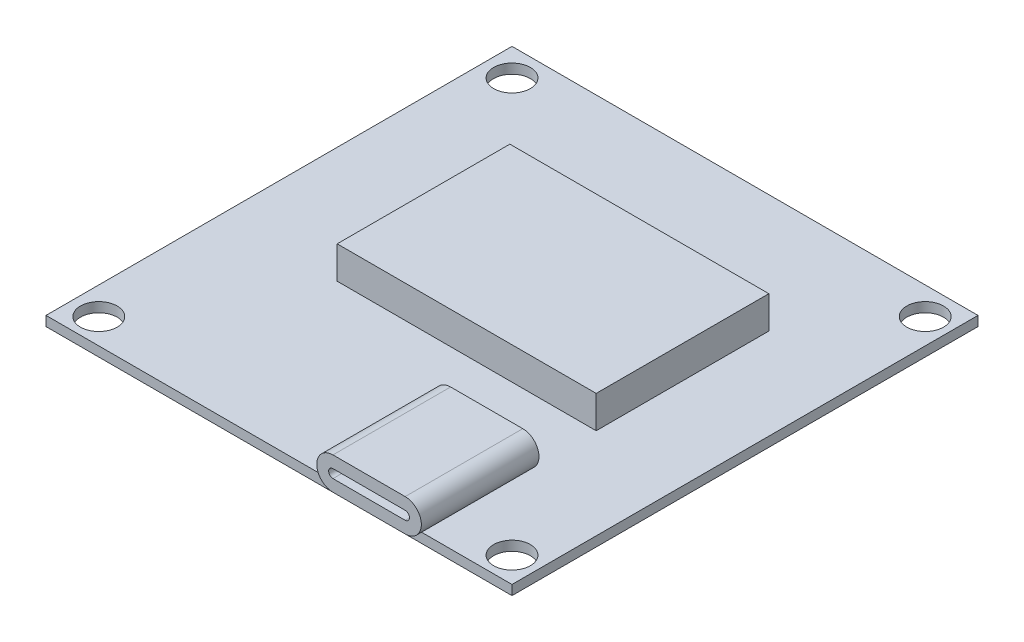
from build123d import *

# Parameters (mm, degrees)
SKETCH1_W                = 43.18
SKETCH1_H                = 43.18
BOSS_EXTRUDE1_DEPTH      = 0.9
SKETCH2_R                = 1.7
CUT_EXTRUDE1_DEPTH       = 0.9
CIRPATTERN1_COUNT        = 4
BOSS_EXTRUDE2_DEPTH      = 0.9
BOSS_EXTRUDE2_DEPTH_BACK = 10
SKETCH5_W                = 24
SKETCH5_H                = 16
BOSS_EXTRUDE3_DEPTH      = 3


with BuildPart() as part:
    # Sketch1 → Boss-Extrude1 (new body)
    with BuildSketch(Plane(origin=(0, 0, 0), x_dir=(1, 0, 0), z_dir=(0, 1, 0))):
        with Locations((21.59, 21.59)):
            Rectangle(SKETCH1_W, SKETCH1_H)
    extrude(amount=BOSS_EXTRUDE1_DEPTH)

    # Sketch2 → Cut-Extrude1 (cut)
    with BuildSketch(Plane(origin=(0, 0.9, 0), x_dir=(1, 0, 0), z_dir=(0, 1, 0))):
        with Locations((2.54, 40.64)):
            Circle(SKETCH2_R)
    cut_extrude1 = extrude(amount=-CUT_EXTRUDE1_DEPTH, mode=Mode.SUBTRACT)

    # CirPattern1: Cut-Extrude1 ×4 about axis
    cirpattern1_axis = Axis((21.683217483, 0, -21.496782517), (0, 1, 0))
    for i in range(1, CIRPATTERN1_COUNT):
        add(cut_extrude1.rotate(cirpattern1_axis, i * 360 / CIRPATTERN1_COUNT), mode=Mode.SUBTRACT)

    # Sketch4 → Boss-Extrude2 (add, two sides)
    with BuildSketch(Plane.XY) as boss_extrude2_sk:
        with BuildLine():
            Line((27.49, 3.9), (34.18, 3.9))
            ThreePointArc((34.18, 3.9), (35.68, 2.4), (34.18, 0.9))
            Line((34.18, 0.9), (27.49, 0.9))
            ThreePointArc((27.49, 0.9), (25.99, 2.4), (27.49, 3.9))
        make_face()
        with BuildLine():
            Line((27.49, 2.8), (34.18, 2.8))
            ThreePointArc((34.18, 2.8), (34.58, 2.4), (34.18, 2))
            Line((34.18, 2), (27.49, 2))
            ThreePointArc((27.49, 2), (27.09, 2.4), (27.49, 2.8))
        make_face(mode=Mode.SUBTRACT)
    extrude(amount=BOSS_EXTRUDE2_DEPTH)
    extrude(boss_extrude2_sk.sketch, amount=-BOSS_EXTRUDE2_DEPTH_BACK)

    # Sketch5 → Boss-Extrude3 (add)
    with BuildSketch(Plane(origin=(0, 0.9, 0), x_dir=(1, 0, 0), z_dir=(0, 1, 0))):
        with Locations((22.747653051, 24.232550554)):
            Rectangle(SKETCH5_W, SKETCH5_H)
    extrude(amount=BOSS_EXTRUDE3_DEPTH)


solid = part.part
